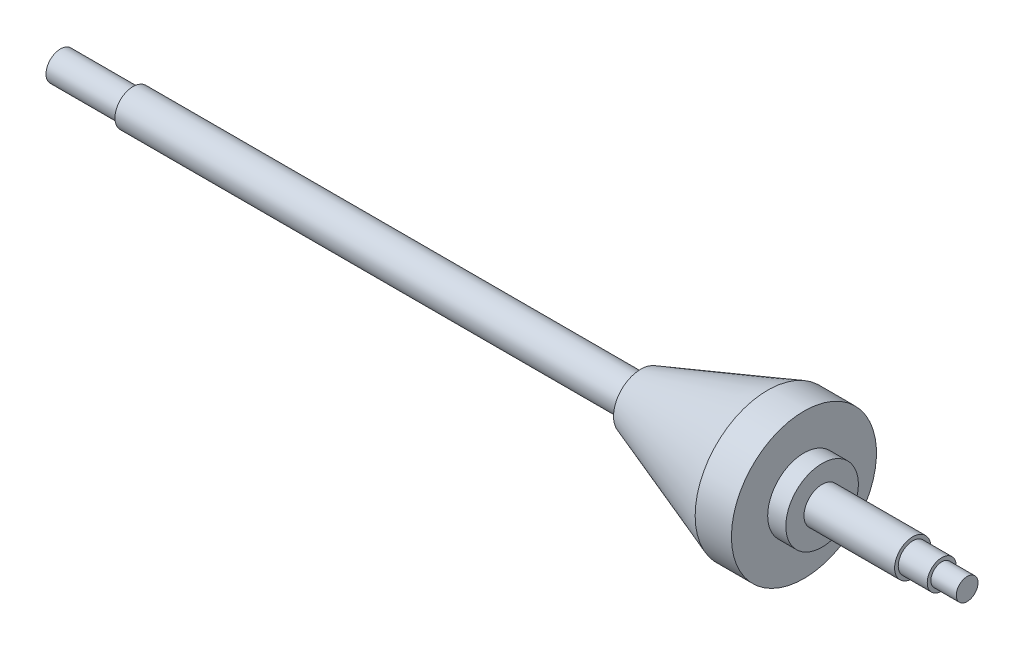
from build123d import *


with BuildPart() as part:
    # Sketch1 → Revolve1 (revolve)
    with BuildSketch(Plane.XY, mode=Mode.PRIVATE) as revolve1_sk:
        Polygon((-36.202328556, 0), (-36.202328556, 4), (-16.202328556, 4), (-16.202328556, 5), (93.797671444, 5), (123.797671444, 5), (123.797671444, 7.5), (158.797671444, 20), (168.797671444, 20), (168.797671444, 10), (173.797671444, 10), (173.797671444, 5), (198.797671444, 5), (198.797671444, 4), (206.797671444, 4), (206.797671444, 3), (213.797671444, 3), (213.797671444, 0), align=None)
    revolve(revolve1_sk.sketch.rotate(Axis((-96.391120084, 0, 0), (1, 0, 0)), 90), axis=Axis((-96.391120084, 0, 0), (1, 0, 0)))  # turned: the seam where the file's is


solid = part.part
